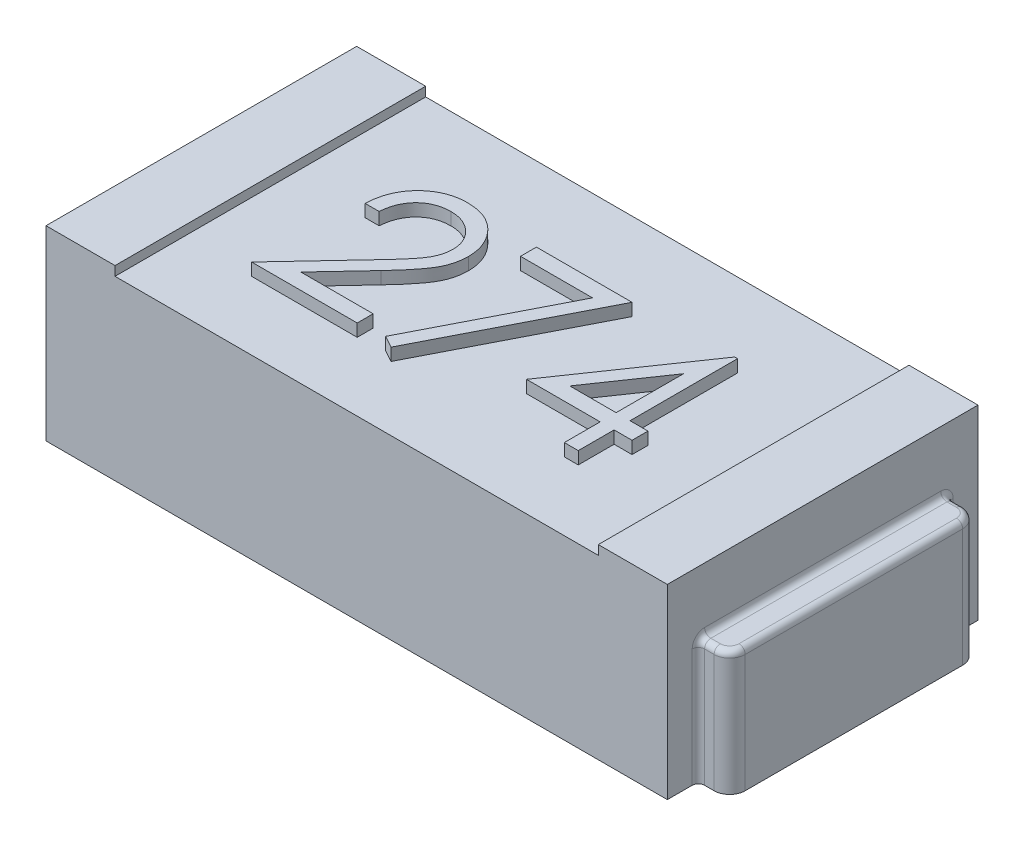
from build123d import *

# Parameters (mm, degrees)
ESQUISSE1_W             = 2
ESQUISSE1_H             = 1
BOSS_EXTRU_1_DEPTH      = 0.6
ESQUISSE2_W             = 1.555645222
ESQUISSE2_H             = 1
ENL_V_MAT_EXTRU_1_DEPTH = 0.03
BOSS_EXTRU_2_DEPTH      = 0.4
CONG_1_R                = 0.02
CONG_1_OF_SYM_TRIE2_R   = 0.02
BOSS_EXTRU_3_DEPTH      = 0.04


with BuildPart() as part:
    # Esquisse1 → Boss.-Extru.1 (new body)
    with BuildSketch(Plane(origin=(0, 0, 0), x_dir=(1, 0, 0), z_dir=(0, 1, 0))):
        Rectangle(ESQUISSE1_W, ESQUISSE1_H)
    extrude(amount=BOSS_EXTRU_1_DEPTH)

    # Esquisse2 → Enlèv. mat.-Extru.1 (cut)
    with BuildSketch(Plane(origin=(0, 0.6, 0), x_dir=(1, 0, 0), z_dir=(0, 1, 0))):
        Rectangle(ESQUISSE2_W, ESQUISSE2_H)
    extrude(amount=-ENL_V_MAT_EXTRU_1_DEPTH, mode=Mode.SUBTRACT)

    # Esquisse3 → Boss.-Extru.2 (add)
    with BuildSketch(Plane(origin=(0, 0, 0), x_dir=(1, 0, 0), z_dir=(0, 1, 0))):
        with BuildLine():
            Line((1, 0.4), (1.050552667, 0.4))
            ThreePointArc((1.050552667, 0.4), (1.085908006, 0.385355339), (1.100552667, 0.35))
            Line((1.100552667, 0.35), (1.100552667, -0.35))
            ThreePointArc((1.100552667, -0.35), (1.085908006, -0.385355339), (1.050552667, -0.4))
            Line((1.050552667, -0.4), (1, -0.4))
            Line((1, -0.4), (1, 0.4))
        make_face()
    boss_extru_2 = extrude(amount=BOSS_EXTRU_2_DEPTH)

    # Congé1
    cong_1_edges = [part.edges().sort_by_distance(p)[0] for p in [
        (1, 0.2, -0.4),
        (1, 0.2, 0.4),
        (1, 0.4, 0),
        (1.025276334, 0.4, 0.4),
        (1.085908006, 0.4, 0.385355339),
        (1.100552667, 0.4, 0),
        (1.085908006, 0.4, -0.385355339),
        (1.025276334, 0.4, -0.4),
    ]]
    fillet(cong_1_edges, radius=CONG_1_R)

    # Symétrie2: Boss.-Extru.2 across plane
    add(boss_extru_2.mirror(Plane(origin=(0, 0, 0), x_dir=(0, 0, 1), z_dir=(1, 0, 0))))

    # Congé1 of Symétrie2
    cong_1_of_sym_trie2_edges = [part.edges().sort_by_distance(p)[0] for p in [
        (-1, 0.2, -0.4),
        (-1, 0.2, 0.4),
        (-1, 0.4, 0),
        (-1.025276334, 0.4, 0.4),
        (-1.085908006, 0.4, 0.385355339),
        (-1.100552667, 0.4, 0),
        (-1.085908006, 0.4, -0.385355339),
        (-1.025276334, 0.4, -0.4),
    ]]
    fillet(cong_1_of_sym_trie2_edges, radius=CONG_1_OF_SYM_TRIE2_R)

    # Esquisse4 → Boss.-Extru.3 (add)
    with BuildSketch(Plane(origin=(0, 0.57, 0), x_dir=(1, 0, 0), z_dir=(0, 1, 0))):
        Polygon((0.48447516, 0.23252099), (0.493589744, 0.23252099), (0.493589744, -0.113632856), (0.551282051, -0.113632856), (0.551282051, -0.164914907), (0.493589744, -0.164914907), (0.493589744, -0.280299523), (0.448717949, -0.280299523), (0.448717949, -0.164914907), (0.211538462, -0.164914907), align=None)
        Polygon((0.448717949, -0.113632856), (0.448717949, 0.10351458), (0.299679487, -0.113632856), align=None, mode=Mode.SUBTRACT)
        Polygon((-0.141025641, 0.219700477), (0.166666667, 0.219700477), (-0.096153846, -0.293120035), (-0.134915865, -0.271785901), (0.090745192, 0.168418426), (-0.141025641, 0.168418426), align=None)
        with BuildLine():
            Line((-0.493589744, 0.065854324), (-0.538461538, 0.065854324))
            add(Edge.make_bspline(
                [(-0.538461538, 0.065854324), (-0.538169088, 0.071807307), (-0.537594723, 0.08349881), (-0.534904968, 0.100545082), (-0.531056271, 0.116838625), (-0.525614635, 0.132248612), (-0.518856595, 0.146911299), (-0.510752305, 0.160768444), (-0.501153184, 0.173767185), (-0.490266507, 0.18578702), (-0.478442416, 0.196813816), (-0.465684425, 0.206335994), (-0.452277992, 0.214381375), (-0.438263792, 0.221107267), (-0.423483712, 0.226155816), (-0.408071875, 0.229901765), (-0.39196057, 0.232155528), (-0.380983424, 0.232397784), (-0.375400641, 0.23252099)],
                knots=[0, 0, 0, 0, 1.7869e-05, 3.5094e-05, 5.1686e-05, 6.8032e-05, 8.4031e-05, 0.000100058, 0.000116104, 0.000132416, 0.000148647, 0.000164532, 0.000180078, 0.00019549, 0.000211074, 0.000226841, 0.000243017, 0.000259759, 0.000259759, 0.000259759, 0.000259759], degree=3))
            add(Edge.make_bspline(
                [(-0.375400641, 0.23252099), (-0.369918059, 0.232392639), (-0.359144981, 0.232140434), (-0.343421836, 0.229974573), (-0.328453651, 0.226582346), (-0.314269685, 0.221823), (-0.300983104, 0.215425225), (-0.288494098, 0.207739862), (-0.276653982, 0.198851315), (-0.26599587, 0.188386485), (-0.256209001, 0.177214715), (-0.247765822, 0.165287872), (-0.24053537, 0.152969403), (-0.234508559, 0.140165374), (-0.230071968, 0.126755227), (-0.226703652, 0.112934198), (-0.224799736, 0.098559225), (-0.224507533, 0.088829717), (-0.224358974, 0.08388317)],
                knots=[0, 0, 0, 0, 1.6441e-05, 3.2306e-05, 4.7516e-05, 6.2435e-05, 7.7085e-05, 9.1652e-05, 0.000106376, 0.000121393, 0.000136374, 0.000150882, 0.000165157, 0.000179183, 0.000193247, 0.000207458, 0.000221808, 0.000236648, 0.000236648, 0.000236648, 0.000236648], degree=3))
            add(Edge.make_bspline(
                [(-0.224358974, 0.08388317), (-0.224600869, 0.076919193), (-0.225080414, 0.063113449), (-0.229182467, 0.042825611), (-0.235589112, 0.023169408), (-0.24330302, 0.007349794), (-0.251084798, -0.005397848), (-0.258097299, -0.015893378), (-0.266306557, -0.027194159), (-0.275832057, -0.03926235), (-0.286476753, -0.052192479), (-0.298337062, -0.065976736), (-0.31149756, -0.080472703), (-0.320734488, -0.090373503), (-0.325520833, -0.09550385)],
                knots=[0, 0, 0, 0, 2.0874e-05, 4.1382e-05, 6.1843e-05, 8.2763e-05, 9.3997e-05, 0.000106637, 0.000120621, 0.000135888, 0.000152753, 0.000170863, 0.000190435, 0.000211484, 0.000211484, 0.000211484, 0.000211484], degree=3))
            Line((-0.325520833, -0.09550385), (-0.450620994, -0.229017471))
            Line((-0.450620994, -0.229017471), (-0.217948718, -0.229017471))
            Line((-0.217948718, -0.229017471), (-0.217948718, -0.280299523))
            Line((-0.217948718, -0.280299523), (-0.557692308, -0.280299523))
            Line((-0.557692308, -0.280299523), (-0.363782051, -0.073368433))
            add(Edge.make_bspline(
                [(-0.363782051, -0.073368433), (-0.359060925, -0.068440103), (-0.349992606, -0.058973791), (-0.337166524, -0.045153368), (-0.325646669, -0.032332005), (-0.31535847, -0.020533927), (-0.306525112, -0.00958656), (-0.298686221, 0.000155541), (-0.292405423, 0.009120462), (-0.285588938, 0.019511978), (-0.27898694, 0.032199452), (-0.273313747, 0.047704265), (-0.269854482, 0.063665301), (-0.269439506, 0.074451306), (-0.269230769, 0.079876759)],
                knots=[0, 0, 0, 0, 2.0474e-05, 3.9327e-05, 5.6561e-05, 7.2184e-05, 8.6278e-05, 9.8762e-05, 0.000109683, 0.000119101, 0.000136035, 0.000152448, 0.000168517, 0.00018478, 0.00018478, 0.00018478, 0.00018478], degree=3))
            add(Edge.make_bspline(
                [(-0.269230769, 0.079876759), (-0.26932159, 0.083288388), (-0.269500579, 0.090012052), (-0.27108025, 0.099870018), (-0.273467465, 0.109379277), (-0.276888216, 0.11856908), (-0.281403465, 0.12734703), (-0.286899662, 0.135723813), (-0.2932411, 0.143822236), (-0.300576995, 0.151415565), (-0.308635784, 0.158370023), (-0.317149248, 0.164530606), (-0.326156406, 0.169679051), (-0.33561928, 0.17389955), (-0.34551149, 0.177210319), (-0.355852168, 0.179504402), (-0.366612742, 0.180944757), (-0.373960384, 0.181139638), (-0.377704327, 0.181238939)],
                knots=[0, 0, 0, 0, 1.0229e-05, 2.0159e-05, 2.9876e-05, 3.9606e-05, 4.9505e-05, 5.9423e-05, 6.9622e-05, 8.0319e-05, 9.1042e-05, 0.000101521, 0.000111795, 0.000122107, 0.000132559, 0.000143032, 0.000153841, 0.00016507, 0.00016507, 0.00016507, 0.00016507], degree=3))
            add(Edge.make_bspline(
                [(-0.377704327, 0.181238939), (-0.381614446, 0.181136791), (-0.389293274, 0.180936191), (-0.400567421, 0.179532953), (-0.411322533, 0.177112119), (-0.421585662, 0.173801165), (-0.431374174, 0.169592801), (-0.440640466, 0.164351123), (-0.449363736, 0.158096338), (-0.457560382, 0.15100483), (-0.465112379, 0.143109459), (-0.471747647, 0.134308036), (-0.477545363, 0.124761262), (-0.482603825, 0.114494898), (-0.486711781, 0.103415786), (-0.489850802, 0.091563257), (-0.492334638, 0.078988774), (-0.493164426, 0.07030519), (-0.493589744, 0.065854324)],
                knots=[0, 0, 0, 0, 1.1729e-05, 2.3035e-05, 3.4018e-05, 4.4756e-05, 5.5343e-05, 6.5928e-05, 7.6628e-05, 8.7492e-05, 9.8403e-05, 0.00010934, 0.000120489, 0.000131867, 0.000143625, 0.00015587, 0.000168619, 0.000182025, 0.000182025, 0.000182025, 0.000182025], degree=3))
        make_face()
    extrude(amount=BOSS_EXTRU_3_DEPTH)


solid = part.part
